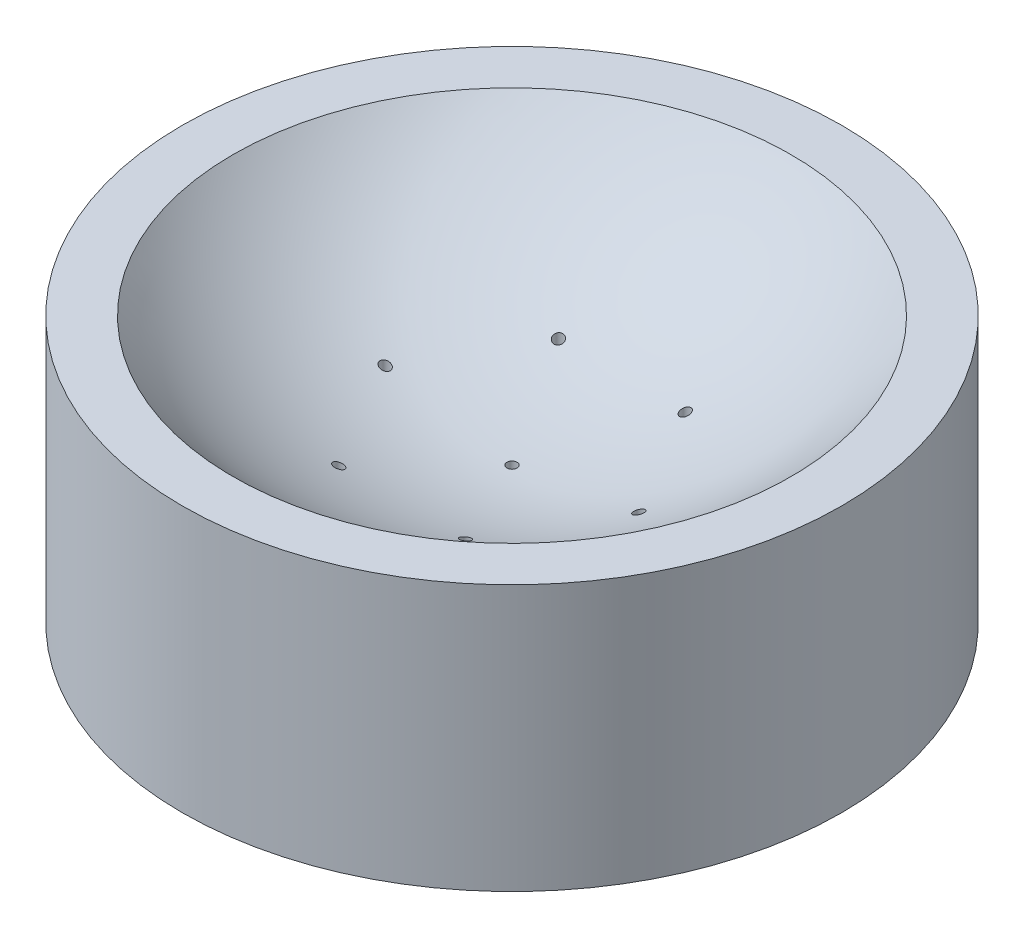
from build123d import *

# Parameters (mm, degrees)
SKETCH4_R           = 1
CUT_EXTRUDE3_DEPTH  = 43.380808577
SKETCH6_R           = 65
SKETCH6_R_2         = 55
BOSS_EXTRUDE1_DEPTH = 10


with BuildPart() as part:
    # Sketch2 → Revolve1 (revolve)
    with BuildSketch(Plane.XY):
        with BuildLine():
            Line((0, -88.845849199), (0, -72))
            ThreePointArc((0, -72), (-30.319276667, -65.304988036), (-55, -46.465040622))
            Line((-55, -46.465040622), (-65, -46.465040622))
            Line((-65, -46.465040622), (-65, -88.845849199))
            Line((-65, -88.845849199), (-55, -88.845849199))
            Line((-55, -88.845849199), (0, -88.845849199))
        make_face()
    revolve(axis=Axis((0, -72, 0), (0, -1, 0)))

    # Sketch4 → Cut-Extrude3 (cut, through all)
    with BuildSketch(Plane.XZ.offset(88.845849199)):
        Circle(SKETCH4_R)
        with Locations((25, 0)):
            Circle(SKETCH4_R)
        with Locations((12.5, -21.650635095)):
            Circle(SKETCH4_R)
        with Locations((-12.5, -21.650635095)):
            Circle(SKETCH4_R)
        with Locations((-25, 0)):
            Circle(SKETCH4_R)
        with Locations((-12.5, 21.650635095)):
            Circle(SKETCH4_R)
        with Locations((12.5, 21.650635095)):
            Circle(SKETCH4_R)
    extrude(amount=-CUT_EXTRUDE3_DEPTH, mode=Mode.SUBTRACT)

    # Sketch6 → Boss-Extrude1 (add)
    with BuildSketch(Plane.XZ.offset(88.845849199)):
        Circle(SKETCH6_R)
        Circle(SKETCH6_R_2, mode=Mode.SUBTRACT)
    extrude(amount=BOSS_EXTRUDE1_DEPTH)


solid = part.part
